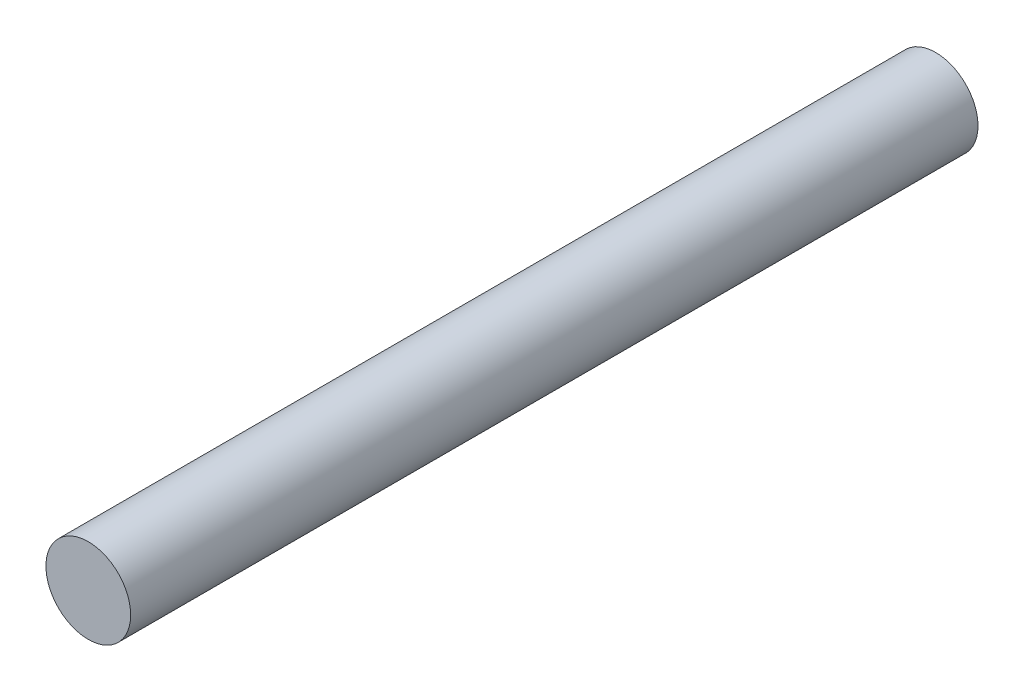
from build123d import *

# Parameters (mm, degrees)
SKETCH1_R           = 10
BOSS_EXTRUDE1_DEPTH = 200


with BuildPart() as part:
    # Sketch1 → Boss-Extrude1 (new body)
    with BuildSketch(Plane.XY):
        Circle(SKETCH1_R)
    extrude(amount=BOSS_EXTRUDE1_DEPTH)


solid = part.part
